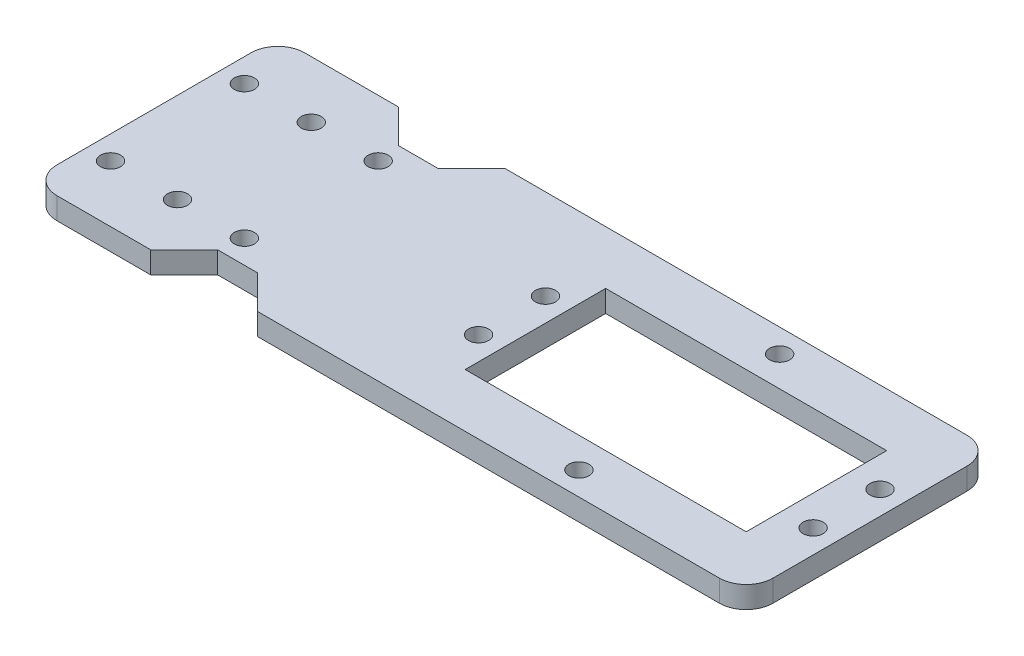
from build123d import *

# Parameters (mm, degrees)
SKETCH1_R           = 1.5025
SKETCH1_W           = 42
SKETCH1_H           = 21
BOSS_EXTRUDE1_DEPTH = 3.25


with BuildPart() as part:
    # Sketch1 → Boss-Extrude1 (new body)
    with BuildSketch(Plane(origin=(0, 0, 0), x_dir=(1, 0, 0), z_dir=(0, 1, 0))):
        with BuildLine():
            Line((-49.5, 18.5), (-35.5, 18.5))
            Line((-35.5, 18.5), (-30.5, 13.5))
            Line((-30.5, 13.5), (-24.5, 13.5))
            Line((-24.5, 13.5), (-19.5, 18.5))
            Line((-19.5, 18.5), (49.5, 18.5))
            ThreePointArc((49.5, 18.5), (52.328427125, 17.328427125), (53.5, 14.5))
            Line((53.5, 14.5), (53.5, -14.5))
            ThreePointArc((53.5, -14.5), (52.328427125, -17.328427125), (49.5, -18.5))
            Line((49.5, -18.5), (-19.5, -18.5))
            Line((-19.5, -18.5), (-24.5, -13.5))
            Line((-24.5, -13.5), (-30.5, -13.5))
            Line((-30.5, -13.5), (-35.5, -18.5))
            Line((-35.5, -18.5), (-49.5, -18.5))
            ThreePointArc((-49.5, -18.5), (-52.328427125, -17.328427125), (-53.5, -14.5))
            Line((-53.5, -14.5), (-53.5, 14.5))
            ThreePointArc((-53.5, 14.5), (-52.328427125, 17.328427125), (-49.5, 18.5))
        make_face()
        with Locations((25, -15)):
            Circle(SKETCH1_R, mode=Mode.SUBTRACT)
        with Locations((-40, -10)):
            Circle(SKETCH1_R, mode=Mode.SUBTRACT)
        with Locations((-30, -10)):
            Circle(SKETCH1_R, mode=Mode.SUBTRACT)
        with Locations((0, -5)):
            Circle(SKETCH1_R, mode=Mode.SUBTRACT)
        with Locations((50, -5)):
            Circle(SKETCH1_R, mode=Mode.SUBTRACT)
        with Locations((0, 5)):
            Circle(SKETCH1_R, mode=Mode.SUBTRACT)
        with Locations((50, 5)):
            Circle(SKETCH1_R, mode=Mode.SUBTRACT)
        with Locations((-40, 10)):
            Circle(SKETCH1_R, mode=Mode.SUBTRACT)
        with Locations((-30, 10)):
            Circle(SKETCH1_R, mode=Mode.SUBTRACT)
        with Locations((25, 15)):
            Circle(SKETCH1_R, mode=Mode.SUBTRACT)
        with Locations((-50, -10)):
            Circle(SKETCH1_R, mode=Mode.SUBTRACT)
        with Locations((-50, 10)):
            Circle(SKETCH1_R, mode=Mode.SUBTRACT)
        with Locations((24.5, 0)):
            Rectangle(SKETCH1_W, SKETCH1_H, mode=Mode.SUBTRACT)
    extrude(amount=BOSS_EXTRUDE1_DEPTH)


solid = part.part
